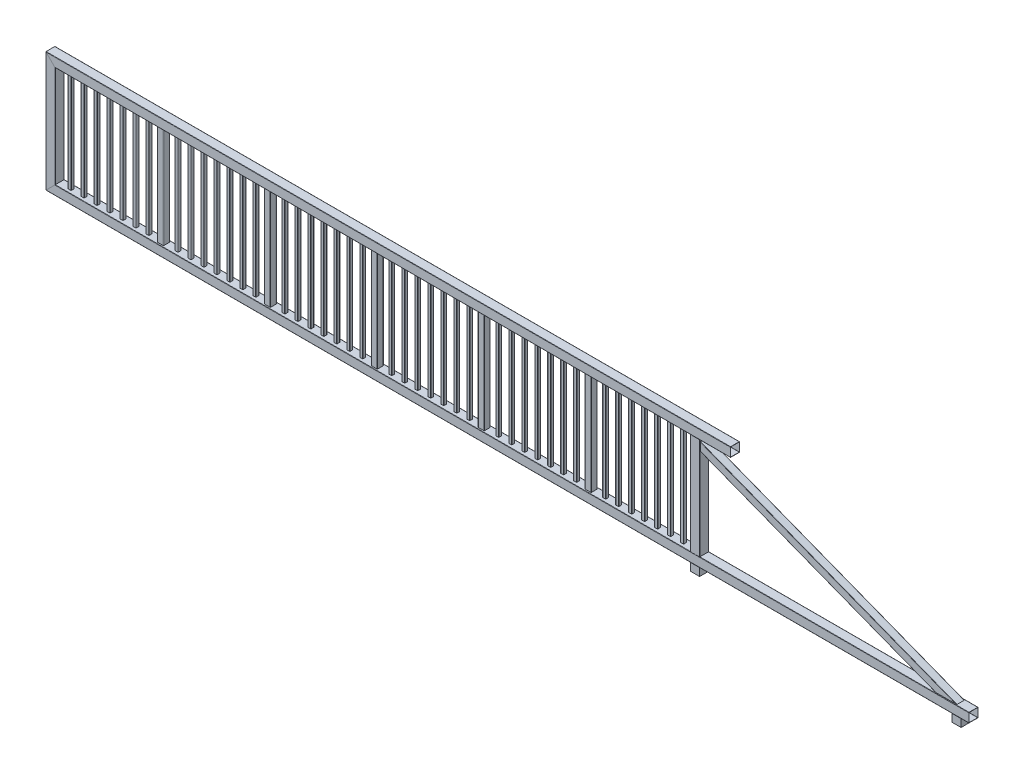
from build123d import *

# Parameters (mm, degrees)
STRUKTURBAUTEIL1_DEPTH               = 12025.852813742
STRUKTURBAUTEIL1_2_DEPTH             = 1611.705627485
STRUKTURBAUTEIL1_3_DEPTH             = 8840
STRUKTURBAUTEIL1_3_DEPTH_BACK        = 85.852813742
STRUKTURBAUTEIL1_4_DEPTH             = 1442
STRUKTURBAUTEIL2_DEPTH               = 1440
STRUKTURBAUTEIL2_2_DEPTH             = 1440
STRUKTURBAUTEIL2_3_DEPTH             = 1440
STRUKTURBAUTEIL2_4_DEPTH             = 1440
STRUKTURBAUTEIL2_5_DEPTH             = 1440
STRUKTURBAUTEIL3_DEPTH               = 3656.569430491
SKIZZE17_W                           = 97.291207045
SKIZZE17_H                           = 66.18861102
SKIZZE17_W_2                         = 105.616150556
SKIZZE17_H_2                         = 110.543827221
SCHNITT_LINEAR_AUSTRAGEN1_DEPTH      = 9026.71880794
SCHNITT_LINEAR_AUSTRAGEN1_DEPTH_BACK = 9026.71880794
STRUKTURBAUTEIL4_DEPTH               = 1320
LINEARES_MUSTER1_COUNT               = 7
LINEARES_MUSTER1_PITCH               = 168.75
LINEARES_MUSTER2_COUNT               = 6
LINEARES_MUSTER2_PITCH               = 1390
SKIZZE27_W                           = 151.392313848
SKIZZE27_H                           = 253.522757627
SCHNITT_LINEAR_AUSTRAGEN2_DEPTH      = 12035.450548322
SKIZZE28_W                           = 120
SKIZZE28_H                           = 120
AUFSATZ_LINEAR_AUSTRAGEN1_DEPTH      = 100
AUFSATZ_LINEAR_AUSTRAGEN1_2_DEPTH    = 100


with BuildPart() as part:
    # Skizze13 on segment 1 (carried to segment 1) → Strukturbauteil1 (new body)
    with BuildSketch(Plane(origin=(11940, 0, 0), x_dir=(0, -1, 0), z_dir=(-1, 0, 0))):
        with BuildLine():
            Line((56, -60), (-56, -60))
            ThreePointArc((-56, -60), (-58.828427125, -58.828427125), (-60, -56))
            Line((-60, -56), (-60, 56))
            ThreePointArc((-60, 56), (-58.828427125, 58.828427125), (-56, 60))
            Line((-56, 60), (56, 60))
            ThreePointArc((56, 60), (58.828427125, 58.828427125), (60, 56))
            Line((60, 56), (60, -56))
            ThreePointArc((60, -56), (58.828427125, -58.828427125), (56, -60))
        make_face()
        with BuildLine():
            Line((57, -56), (57, 56))
            ThreePointArc((57, 56), (56.707106781, 56.707106781), (56, 57))
            Line((56, 57), (-56, 57))
            ThreePointArc((-56, 57), (-56.707106781, 56.707106781), (-57, 56))
            Line((-57, 56), (-57, -56))
            ThreePointArc((-57, -56), (-56.707106781, -56.707106781), (-56, -57))
            Line((-56, -57), (56, -57))
            ThreePointArc((56, -57), (56.707106781, -56.707106781), (57, -56))
        make_face(mode=Mode.SUBTRACT)
    extrude(amount=STRUKTURBAUTEIL1_DEPTH)

    # Strukturbauteil1 mitre 1
    split(bisect_by=Plane(origin=(0, 0, 0), x_dir=(0.707106781, 0.707106781, 0), z_dir=(0.707106781, -0.707106781, 0)), keep=Keep.TOP)


with BuildPart() as body_2:
    # Skizze13 on segment 2 (carried to segment 2) → Strukturbauteil1 2 (new body)
    with BuildSketch(Plane(origin=(0, -85.852813742, 0), x_dir=(-1, 0, 0), z_dir=(0, 1, 0))):
        with BuildLine():
            Line((56, -60), (-56, -60))
            ThreePointArc((-56, -60), (-58.828427125, -58.828427125), (-60, -56))
            Line((-60, -56), (-60, 56))
            ThreePointArc((-60, 56), (-58.828427125, 58.828427125), (-56, 60))
            Line((-56, 60), (56, 60))
            ThreePointArc((56, 60), (58.828427125, 58.828427125), (60, 56))
            Line((60, 56), (60, -56))
            ThreePointArc((60, -56), (58.828427125, -58.828427125), (56, -60))
        make_face()
        with BuildLine():
            Line((57, -56), (57, 56))
            ThreePointArc((57, 56), (56.707106781, 56.707106781), (56, 57))
            Line((56, 57), (-56, 57))
            ThreePointArc((-56, 57), (-56.707106781, 56.707106781), (-57, 56))
            Line((-57, 56), (-57, -56))
            ThreePointArc((-57, -56), (-56.707106781, -56.707106781), (-56, -57))
            Line((-56, -57), (56, -57))
            ThreePointArc((56, -57), (56.707106781, -56.707106781), (57, -56))
        make_face(mode=Mode.SUBTRACT)
    extrude(amount=STRUKTURBAUTEIL1_2_DEPTH)

    # Strukturbauteil1 2 mitre 1
    split(bisect_by=Plane(origin=(0, 0, 0), x_dir=(-0.707106781, -0.707106781, 0), z_dir=(-0.707106781, 0.707106781, 0)), keep=Keep.TOP)

    # Strukturbauteil1 2 mitre 2
    split(bisect_by=Plane(origin=(0, 1440, 0), x_dir=(0.707106781, -0.707106781, 0), z_dir=(-0.707106781, -0.707106781, 0)), keep=Keep.TOP)


with BuildPart() as body_3:
    # Skizze13 → Strukturbauteil1 3 (new, two sides)
    with BuildSketch(Plane(origin=(0, 1440, 0), x_dir=(0, 1, 0), z_dir=(1, 0, 0))) as strukturbauteil1_3_sk:
        with BuildLine():
            Line((56, -60), (-56, -60))
            ThreePointArc((-56, -60), (-58.828427125, -58.828427125), (-60, -56))
            Line((-60, -56), (-60, 56))
            ThreePointArc((-60, 56), (-58.828427125, 58.828427125), (-56, 60))
            Line((-56, 60), (56, 60))
            ThreePointArc((56, 60), (58.828427125, 58.828427125), (60, 56))
            Line((60, 56), (60, -56))
            ThreePointArc((60, -56), (58.828427125, -58.828427125), (56, -60))
        make_face()
        with BuildLine():
            Line((57, -56), (57, 56))
            ThreePointArc((57, 56), (56.707106781, 56.707106781), (56, 57))
            Line((56, 57), (-56, 57))
            ThreePointArc((-56, 57), (-56.707106781, 56.707106781), (-57, 56))
            Line((-57, 56), (-57, -56))
            ThreePointArc((-57, -56), (-56.707106781, -56.707106781), (-56, -57))
            Line((-56, -57), (56, -57))
            ThreePointArc((56, -57), (56.707106781, -56.707106781), (57, -56))
        make_face(mode=Mode.SUBTRACT)
    extrude(amount=STRUKTURBAUTEIL1_3_DEPTH)
    extrude(strukturbauteil1_3_sk.sketch, amount=-STRUKTURBAUTEIL1_3_DEPTH_BACK)

    # Strukturbauteil1 3 mitre 1
    split(bisect_by=Plane(origin=(0, 1440, 0), x_dir=(-0.707106781, 0.707106781, 0), z_dir=(0.707106781, 0.707106781, 0)), keep=Keep.TOP)


with BuildPart() as body_4:
    # Skizze13 on segment 4 (carried to segment 4) → Strukturbauteil1 4 (new body)
    with BuildSketch(Plane(origin=(8380, 1441, 0), x_dir=(1, 0, 0), z_dir=(0, -1, 0))):
        with BuildLine():
            Line((56, -60), (-56, -60))
            ThreePointArc((-56, -60), (-58.828427125, -58.828427125), (-60, -56))
            Line((-60, -56), (-60, 56))
            ThreePointArc((-60, 56), (-58.828427125, 58.828427125), (-56, 60))
            Line((-56, 60), (56, 60))
            ThreePointArc((56, 60), (58.828427125, 58.828427125), (60, 56))
            Line((60, 56), (60, -56))
            ThreePointArc((60, -56), (58.828427125, -58.828427125), (56, -60))
        make_face()
        with BuildLine():
            Line((57, -56), (57, 56))
            ThreePointArc((57, 56), (56.707106781, 56.707106781), (56, 57))
            Line((56, 57), (-56, 57))
            ThreePointArc((-56, 57), (-56.707106781, 56.707106781), (-57, 56))
            Line((-57, 56), (-57, -56))
            ThreePointArc((-57, -56), (-56.707106781, -56.707106781), (-56, -57))
            Line((-56, -57), (56, -57))
            ThreePointArc((56, -57), (56.707106781, -56.707106781), (57, -56))
        make_face(mode=Mode.SUBTRACT)
    extrude(amount=STRUKTURBAUTEIL1_4_DEPTH)

    # Strukturbauteil1 4 mitre 1
    split(bisect_by=Plane(origin=(8380, 1380, 0), x_dir=(1, 0, 0), z_dir=(0, -1, 0)), keep=Keep.TOP)

    # Strukturbauteil1 4 mitre 2
    split(bisect_by=Plane(origin=(8380, 60, 0), x_dir=(-1, 0, 0), z_dir=(0, 1, 0)), keep=Keep.TOP)


with BuildPart() as body_5:
    # Skizze14 → Strukturbauteil2 (new body)
    with BuildSketch(Plane(origin=(1410, 1440, 0), x_dir=(1, 0, 0), z_dir=(0, -1, 0))):
        with BuildLine():
            Line((36, -40), (-36, -40))
            ThreePointArc((-36, -40), (-38.828427125, -38.828427125), (-40, -36))
            Line((-40, -36), (-40, 36))
            ThreePointArc((-40, 36), (-38.828427125, 38.828427125), (-36, 40))
            Line((-36, 40), (36, 40))
            ThreePointArc((36, 40), (38.828427125, 38.828427125), (40, 36))
            Line((40, 36), (40, -36))
            ThreePointArc((40, -36), (38.828427125, -38.828427125), (36, -40))
        make_face()
        with BuildLine():
            Line((37, -36), (37, 36))
            ThreePointArc((37, 36), (36.707106781, 36.707106781), (36, 37))
            Line((36, 37), (-36, 37))
            ThreePointArc((-36, 37), (-36.707106781, 36.707106781), (-37, 36))
            Line((-37, 36), (-37, -36))
            ThreePointArc((-37, -36), (-36.707106781, -36.707106781), (-36, -37))
            Line((-36, -37), (36, -37))
            ThreePointArc((36, -37), (36.707106781, -36.707106781), (37, -36))
        make_face(mode=Mode.SUBTRACT)
    extrude(amount=STRUKTURBAUTEIL2_DEPTH)


with BuildPart() as body_6:
    # Skizze14 on segment 2 (carried to segment 2) → Strukturbauteil2 2 (new body)
    with BuildSketch(Plane(origin=(2800, 1440, 0), x_dir=(1, 0, 0), z_dir=(0, -1, 0))):
        with BuildLine():
            Line((36, -40), (-36, -40))
            ThreePointArc((-36, -40), (-38.828427125, -38.828427125), (-40, -36))
            Line((-40, -36), (-40, 36))
            ThreePointArc((-40, 36), (-38.828427125, 38.828427125), (-36, 40))
            Line((-36, 40), (36, 40))
            ThreePointArc((36, 40), (38.828427125, 38.828427125), (40, 36))
            Line((40, 36), (40, -36))
            ThreePointArc((40, -36), (38.828427125, -38.828427125), (36, -40))
        make_face()
        with BuildLine():
            Line((37, -36), (37, 36))
            ThreePointArc((37, 36), (36.707106781, 36.707106781), (36, 37))
            Line((36, 37), (-36, 37))
            ThreePointArc((-36, 37), (-36.707106781, 36.707106781), (-37, 36))
            Line((-37, 36), (-37, -36))
            ThreePointArc((-37, -36), (-36.707106781, -36.707106781), (-36, -37))
            Line((-36, -37), (36, -37))
            ThreePointArc((36, -37), (36.707106781, -36.707106781), (37, -36))
        make_face(mode=Mode.SUBTRACT)
    extrude(amount=STRUKTURBAUTEIL2_2_DEPTH)


with BuildPart() as body_7:
    # Skizze14 on segment 3 (carried to segment 3) → Strukturbauteil2 3 (new body)
    with BuildSketch(Plane(origin=(4190, 1440, 0), x_dir=(1, 0, 0), z_dir=(0, -1, 0))):
        with BuildLine():
            Line((36, -40), (-36, -40))
            ThreePointArc((-36, -40), (-38.828427125, -38.828427125), (-40, -36))
            Line((-40, -36), (-40, 36))
            ThreePointArc((-40, 36), (-38.828427125, 38.828427125), (-36, 40))
            Line((-36, 40), (36, 40))
            ThreePointArc((36, 40), (38.828427125, 38.828427125), (40, 36))
            Line((40, 36), (40, -36))
            ThreePointArc((40, -36), (38.828427125, -38.828427125), (36, -40))
        make_face()
        with BuildLine():
            Line((37, -36), (37, 36))
            ThreePointArc((37, 36), (36.707106781, 36.707106781), (36, 37))
            Line((36, 37), (-36, 37))
            ThreePointArc((-36, 37), (-36.707106781, 36.707106781), (-37, 36))
            Line((-37, 36), (-37, -36))
            ThreePointArc((-37, -36), (-36.707106781, -36.707106781), (-36, -37))
            Line((-36, -37), (36, -37))
            ThreePointArc((36, -37), (36.707106781, -36.707106781), (37, -36))
        make_face(mode=Mode.SUBTRACT)
    extrude(amount=STRUKTURBAUTEIL2_3_DEPTH)


with BuildPart() as body_8:
    # Skizze14 on segment 4 (carried to segment 4) → Strukturbauteil2 4 (new body)
    with BuildSketch(Plane(origin=(5580, 1440, 0), x_dir=(1, 0, 0), z_dir=(0, -1, 0))):
        with BuildLine():
            Line((36, -40), (-36, -40))
            ThreePointArc((-36, -40), (-38.828427125, -38.828427125), (-40, -36))
            Line((-40, -36), (-40, 36))
            ThreePointArc((-40, 36), (-38.828427125, 38.828427125), (-36, 40))
            Line((-36, 40), (36, 40))
            ThreePointArc((36, 40), (38.828427125, 38.828427125), (40, 36))
            Line((40, 36), (40, -36))
            ThreePointArc((40, -36), (38.828427125, -38.828427125), (36, -40))
        make_face()
        with BuildLine():
            Line((37, -36), (37, 36))
            ThreePointArc((37, 36), (36.707106781, 36.707106781), (36, 37))
            Line((36, 37), (-36, 37))
            ThreePointArc((-36, 37), (-36.707106781, 36.707106781), (-37, 36))
            Line((-37, 36), (-37, -36))
            ThreePointArc((-37, -36), (-36.707106781, -36.707106781), (-36, -37))
            Line((-36, -37), (36, -37))
            ThreePointArc((36, -37), (36.707106781, -36.707106781), (37, -36))
        make_face(mode=Mode.SUBTRACT)
    extrude(amount=STRUKTURBAUTEIL2_4_DEPTH)


with BuildPart() as body_9:
    # Skizze14 on segment 5 (carried to segment 5) → Strukturbauteil2 5 (new body)
    with BuildSketch(Plane(origin=(6970, 1440, 0), x_dir=(1, 0, 0), z_dir=(0, -1, 0))):
        with BuildLine():
            Line((36, -40), (-36, -40))
            ThreePointArc((-36, -40), (-38.828427125, -38.828427125), (-40, -36))
            Line((-40, -36), (-40, 36))
            ThreePointArc((-40, 36), (-38.828427125, 38.828427125), (-36, 40))
            Line((-36, 40), (36, 40))
            ThreePointArc((36, 40), (38.828427125, 38.828427125), (40, 36))
            Line((40, 36), (40, -36))
            ThreePointArc((40, -36), (38.828427125, -38.828427125), (36, -40))
        make_face()
        with BuildLine():
            Line((37, -36), (37, 36))
            ThreePointArc((37, 36), (36.707106781, 36.707106781), (36, 37))
            Line((36, 37), (-36, 37))
            ThreePointArc((-36, 37), (-36.707106781, 36.707106781), (-37, 36))
            Line((-37, 36), (-37, -36))
            ThreePointArc((-37, -36), (-36.707106781, -36.707106781), (-36, -37))
            Line((-36, -37), (36, -37))
            ThreePointArc((36, -37), (36.707106781, -36.707106781), (37, -36))
        make_face(mode=Mode.SUBTRACT)
    extrude(amount=STRUKTURBAUTEIL2_5_DEPTH)


with BuildPart() as body_10:
    # Skizze16 → Strukturbauteil3 (new body)
    with BuildSketch(Plane(origin=(8380, 1320, 0), x_dir=(0.36099410255771225, 0.9325680982740896, 0), z_dir=(0.9325680982740896, -0.36099410255771225, 0))):
        with BuildLine():
            Line((46, -50), (-46, -50))
            ThreePointArc((-46, -50), (-48.828427125, -48.828427125), (-50, -46))
            Line((-50, -46), (-50, 46))
            ThreePointArc((-50, 46), (-48.828427125, 48.828427125), (-46, 50))
            Line((-46, 50), (46, 50))
            ThreePointArc((46, 50), (48.828427125, 48.828427125), (50, 46))
            Line((50, 46), (50, -46))
            ThreePointArc((50, -46), (48.828427125, -48.828427125), (46, -50))
        make_face()
        with BuildLine():
            Line((47, -46), (47, 46))
            ThreePointArc((47, 46), (46.707106781, 46.707106781), (46, 47))
            Line((46, 47), (-46, 47))
            ThreePointArc((-46, 47), (-46.707106781, 46.707106781), (-47, 46))
            Line((-47, 46), (-47, -46))
            ThreePointArc((-47, -46), (-46.707106781, -46.707106781), (-46, -47))
            Line((-46, -47), (46, -47))
            ThreePointArc((46, -47), (46.707106781, -46.707106781), (47, -46))
        make_face(mode=Mode.SUBTRACT)
    extrude(amount=STRUKTURBAUTEIL3_DEPTH)


with BuildPart() as schnitt_linear_austragen1_tool:
    # Skizze17 → Schnitt-Linear austragen1 (new, two sides)
    with BuildSketch(Plane(origin=(8840, 0, 0), x_dir=(0, 0, -1), z_dir=(1, 0, 0))) as schnitt_linear_austragen1_sk:
        with Locations((0.592212459, 1413.09430551)):
            Rectangle(SKIZZE17_W, SKIZZE17_H)
        with Locations((0.13209474, 4.72808639)):
            Rectangle(SKIZZE17_W_2, SKIZZE17_H_2)
    extrude(amount=SCHNITT_LINEAR_AUSTRAGEN1_DEPTH)
    extrude(schnitt_linear_austragen1_sk.sketch, amount=-SCHNITT_LINEAR_AUSTRAGEN1_DEPTH_BACK)


with BuildPart() as body_9_1:
    add(body_9.part)

    # Schnitt-Linear austragen1: cut by schnitt_linear_austragen1_tool
    add(schnitt_linear_austragen1_tool.part, mode=Mode.SUBTRACT)


with BuildPart() as body_8_1:
    add(body_8.part)

    # Schnitt-Linear austragen1: cut by schnitt_linear_austragen1_tool
    add(schnitt_linear_austragen1_tool.part, mode=Mode.SUBTRACT)


with BuildPart() as body_7_1:
    add(body_7.part)

    # Schnitt-Linear austragen1: cut by schnitt_linear_austragen1_tool
    add(schnitt_linear_austragen1_tool.part, mode=Mode.SUBTRACT)


with BuildPart() as body_6_1:
    add(body_6.part)

    # Schnitt-Linear austragen1: cut by schnitt_linear_austragen1_tool
    add(schnitt_linear_austragen1_tool.part, mode=Mode.SUBTRACT)


with BuildPart() as body_5_1:
    add(body_5.part)

    # Schnitt-Linear austragen1: cut by schnitt_linear_austragen1_tool
    add(schnitt_linear_austragen1_tool.part, mode=Mode.SUBTRACT)


with BuildPart() as body_10_1:
    add(body_10.part)

    # Schnitt-Linear austragen1: cut by schnitt_linear_austragen1_tool
    add(schnitt_linear_austragen1_tool.part, mode=Mode.SUBTRACT)

    # Skizze27 → Schnitt-Linear austragen2 (cut, through all)
    with BuildSketch(Plane.XY.offset(60)):
        with Locations((8364.303843076, 1336.173716669)):
            Rectangle(SKIZZE27_W, SKIZZE27_H)
    extrude(amount=-SCHNITT_LINEAR_AUSTRAGEN2_DEPTH, mode=Mode.SUBTRACT)


with BuildPart() as body_11:
    # Skizze19 → Strukturbauteil4 (new body)
    with BuildSketch(Plane(origin=(208.75, 1380, 0), x_dir=(1, 0, 0), z_dir=(0, -1, 0))):
        with BuildLine():
            Line((16.5, -20), (-16.5, -20))
            ThreePointArc((-16.5, -20), (-18.974873734, -18.974873734), (-20, -16.5))
            Line((-20, -16.5), (-20, 16.5))
            ThreePointArc((-20, 16.5), (-18.974873734, 18.974873734), (-16.5, 20))
            Line((-16.5, 20), (16.5, 20))
            ThreePointArc((16.5, 20), (18.974873734, 18.974873734), (20, 16.5))
            Line((20, 16.5), (20, -16.5))
            ThreePointArc((20, -16.5), (18.974873734, -18.974873734), (16.5, -20))
        make_face()
        with BuildLine():
            Line((17.5, -16.5), (17.5, 16.5))
            ThreePointArc((17.5, 16.5), (17.207106781, 17.207106781), (16.5, 17.5))
            Line((16.5, 17.5), (-16.5, 17.5))
            ThreePointArc((-16.5, 17.5), (-17.207106781, 17.207106781), (-17.5, 16.5))
            Line((-17.5, 16.5), (-17.5, -16.5))
            ThreePointArc((-17.5, -16.5), (-17.207106781, -17.207106781), (-16.5, -17.5))
            Line((-16.5, -17.5), (16.5, -17.5))
            ThreePointArc((16.5, -17.5), (17.207106781, -17.207106781), (17.5, -16.5))
        make_face(mode=Mode.SUBTRACT)
    extrude(amount=STRUKTURBAUTEIL4_DEPTH)


with BuildPart() as lineares_muster1_1:
    # Lineares Muster1: pattern copy
    add(body_11.part.moved(Location(Vector(1, 0, 0) * (1 * LINEARES_MUSTER1_PITCH))))


with BuildPart() as lineares_muster1_2:
    # Lineares Muster1: pattern copy
    add(body_11.part.moved(Location(Vector(1, 0, 0) * (2 * LINEARES_MUSTER1_PITCH))))


with BuildPart() as lineares_muster1_3:
    # Lineares Muster1: pattern copy
    add(body_11.part.moved(Location(Vector(1, 0, 0) * (3 * LINEARES_MUSTER1_PITCH))))


with BuildPart() as lineares_muster1_4:
    # Lineares Muster1: pattern copy
    add(body_11.part.moved(Location(Vector(1, 0, 0) * (4 * LINEARES_MUSTER1_PITCH))))


with BuildPart() as lineares_muster1_5:
    # Lineares Muster1: pattern copy
    add(body_11.part.moved(Location(Vector(1, 0, 0) * (5 * LINEARES_MUSTER1_PITCH))))


with BuildPart() as lineares_muster1_6:
    # Lineares Muster1: pattern copy
    add(body_11.part.moved(Location(Vector(1, 0, 0) * (6 * LINEARES_MUSTER1_PITCH))))


with BuildPart() as lineares_muster2_1:
    # Lineares Muster2: pattern copy
    add(lineares_muster1_6.part.moved(Location(Vector(1, 0, 0) * (1 * LINEARES_MUSTER2_PITCH))))


with BuildPart() as lineares_muster2_2:
    # Lineares Muster2: pattern copy
    add(lineares_muster1_6.part.moved(Location(Vector(1, 0, 0) * (2 * LINEARES_MUSTER2_PITCH))))


with BuildPart() as lineares_muster2_3:
    # Lineares Muster2: pattern copy
    add(lineares_muster1_6.part.moved(Location(Vector(1, 0, 0) * (3 * LINEARES_MUSTER2_PITCH))))


with BuildPart() as lineares_muster2_4:
    # Lineares Muster2: pattern copy
    add(lineares_muster1_6.part.moved(Location(Vector(1, 0, 0) * (4 * LINEARES_MUSTER2_PITCH))))


with BuildPart() as lineares_muster2_5:
    # Lineares Muster2: pattern copy
    add(lineares_muster1_6.part.moved(Location(Vector(1, 0, 0) * (5 * LINEARES_MUSTER2_PITCH))))


with BuildPart() as lineares_muster2_6:
    # Lineares Muster2: pattern copy
    add(lineares_muster1_5.part.moved(Location(Vector(1, 0, 0) * (1 * LINEARES_MUSTER2_PITCH))))


with BuildPart() as lineares_muster2_7:
    # Lineares Muster2: pattern copy
    add(lineares_muster1_5.part.moved(Location(Vector(1, 0, 0) * (2 * LINEARES_MUSTER2_PITCH))))


with BuildPart() as lineares_muster2_8:
    # Lineares Muster2: pattern copy
    add(lineares_muster1_5.part.moved(Location(Vector(1, 0, 0) * (3 * LINEARES_MUSTER2_PITCH))))


with BuildPart() as lineares_muster2_9:
    # Lineares Muster2: pattern copy
    add(lineares_muster1_5.part.moved(Location(Vector(1, 0, 0) * (4 * LINEARES_MUSTER2_PITCH))))


with BuildPart() as lineares_muster2_10:
    # Lineares Muster2: pattern copy
    add(lineares_muster1_5.part.moved(Location(Vector(1, 0, 0) * (5 * LINEARES_MUSTER2_PITCH))))


with BuildPart() as lineares_muster2_11:
    # Lineares Muster2: pattern copy
    add(lineares_muster1_4.part.moved(Location(Vector(1, 0, 0) * (1 * LINEARES_MUSTER2_PITCH))))


with BuildPart() as lineares_muster2_12:
    # Lineares Muster2: pattern copy
    add(lineares_muster1_4.part.moved(Location(Vector(1, 0, 0) * (2 * LINEARES_MUSTER2_PITCH))))


with BuildPart() as lineares_muster2_13:
    # Lineares Muster2: pattern copy
    add(lineares_muster1_4.part.moved(Location(Vector(1, 0, 0) * (3 * LINEARES_MUSTER2_PITCH))))


with BuildPart() as lineares_muster2_14:
    # Lineares Muster2: pattern copy
    add(lineares_muster1_4.part.moved(Location(Vector(1, 0, 0) * (4 * LINEARES_MUSTER2_PITCH))))


with BuildPart() as lineares_muster2_15:
    # Lineares Muster2: pattern copy
    add(lineares_muster1_4.part.moved(Location(Vector(1, 0, 0) * (5 * LINEARES_MUSTER2_PITCH))))


with BuildPart() as lineares_muster2_16:
    # Lineares Muster2: pattern copy
    add(lineares_muster1_3.part.moved(Location(Vector(1, 0, 0) * (1 * LINEARES_MUSTER2_PITCH))))


with BuildPart() as lineares_muster2_17:
    # Lineares Muster2: pattern copy
    add(lineares_muster1_3.part.moved(Location(Vector(1, 0, 0) * (2 * LINEARES_MUSTER2_PITCH))))


with BuildPart() as lineares_muster2_18:
    # Lineares Muster2: pattern copy
    add(lineares_muster1_3.part.moved(Location(Vector(1, 0, 0) * (3 * LINEARES_MUSTER2_PITCH))))


with BuildPart() as lineares_muster2_19:
    # Lineares Muster2: pattern copy
    add(lineares_muster1_3.part.moved(Location(Vector(1, 0, 0) * (4 * LINEARES_MUSTER2_PITCH))))


with BuildPart() as lineares_muster2_20:
    # Lineares Muster2: pattern copy
    add(lineares_muster1_3.part.moved(Location(Vector(1, 0, 0) * (5 * LINEARES_MUSTER2_PITCH))))


with BuildPart() as lineares_muster2_21:
    # Lineares Muster2: pattern copy
    add(lineares_muster1_2.part.moved(Location(Vector(1, 0, 0) * (1 * LINEARES_MUSTER2_PITCH))))


with BuildPart() as lineares_muster2_22:
    # Lineares Muster2: pattern copy
    add(lineares_muster1_2.part.moved(Location(Vector(1, 0, 0) * (2 * LINEARES_MUSTER2_PITCH))))


with BuildPart() as lineares_muster2_23:
    # Lineares Muster2: pattern copy
    add(lineares_muster1_2.part.moved(Location(Vector(1, 0, 0) * (3 * LINEARES_MUSTER2_PITCH))))


with BuildPart() as lineares_muster2_24:
    # Lineares Muster2: pattern copy
    add(lineares_muster1_2.part.moved(Location(Vector(1, 0, 0) * (4 * LINEARES_MUSTER2_PITCH))))


with BuildPart() as lineares_muster2_25:
    # Lineares Muster2: pattern copy
    add(lineares_muster1_2.part.moved(Location(Vector(1, 0, 0) * (5 * LINEARES_MUSTER2_PITCH))))


with BuildPart() as lineares_muster2_26:
    # Lineares Muster2: pattern copy
    add(lineares_muster1_1.part.moved(Location(Vector(1, 0, 0) * (1 * LINEARES_MUSTER2_PITCH))))


with BuildPart() as lineares_muster2_27:
    # Lineares Muster2: pattern copy
    add(lineares_muster1_1.part.moved(Location(Vector(1, 0, 0) * (2 * LINEARES_MUSTER2_PITCH))))


with BuildPart() as lineares_muster2_28:
    # Lineares Muster2: pattern copy
    add(lineares_muster1_1.part.moved(Location(Vector(1, 0, 0) * (3 * LINEARES_MUSTER2_PITCH))))


with BuildPart() as lineares_muster2_29:
    # Lineares Muster2: pattern copy
    add(lineares_muster1_1.part.moved(Location(Vector(1, 0, 0) * (4 * LINEARES_MUSTER2_PITCH))))


with BuildPart() as lineares_muster2_30:
    # Lineares Muster2: pattern copy
    add(lineares_muster1_1.part.moved(Location(Vector(1, 0, 0) * (5 * LINEARES_MUSTER2_PITCH))))


with BuildPart() as lineares_muster2_31:
    # Lineares Muster2: pattern copy
    add(body_11.part.moved(Location(Vector(1, 0, 0) * (1 * LINEARES_MUSTER2_PITCH))))


with BuildPart() as lineares_muster2_32:
    # Lineares Muster2: pattern copy
    add(body_11.part.moved(Location(Vector(1, 0, 0) * (2 * LINEARES_MUSTER2_PITCH))))


with BuildPart() as lineares_muster2_33:
    # Lineares Muster2: pattern copy
    add(body_11.part.moved(Location(Vector(1, 0, 0) * (3 * LINEARES_MUSTER2_PITCH))))


with BuildPart() as lineares_muster2_34:
    # Lineares Muster2: pattern copy
    add(body_11.part.moved(Location(Vector(1, 0, 0) * (4 * LINEARES_MUSTER2_PITCH))))


with BuildPart() as lineares_muster2_35:
    # Lineares Muster2: pattern copy
    add(body_11.part.moved(Location(Vector(1, 0, 0) * (5 * LINEARES_MUSTER2_PITCH))))


with BuildPart() as body_53:
    # Skizze28 → Aufsatz-Linear austragen1 (new body)
    with BuildSketch(Plane(origin=(0, -60, 0), x_dir=(-1, 0, 0), z_dir=(0, -1, 0))):
        with Locations((-8380, 0)):
            Rectangle(SKIZZE28_W, SKIZZE28_H)
    extrude(amount=AUFSATZ_LINEAR_AUSTRAGEN1_DEPTH)


with BuildPart() as body_54:
    # Skizze28 → Aufsatz-Linear austragen1 2 (new body)
    with BuildSketch(Plane(origin=(0, -60, 0), x_dir=(-1, 0, 0), z_dir=(0, -1, 0))):
        with Locations((-11780, 0)):
            Rectangle(SKIZZE28_W, SKIZZE28_H)
    extrude(amount=AUFSATZ_LINEAR_AUSTRAGEN1_2_DEPTH)


solid = Compound([part.part, body_2.part, body_3.part, body_4.part, body_9_1.part, body_8_1.part, body_7_1.part, body_6_1.part, body_5_1.part, body_10_1.part, body_11.part, lineares_muster1_1.part, lineares_muster1_2.part, lineares_muster1_3.part, lineares_muster1_4.part, lineares_muster1_5.part, lineares_muster1_6.part, lineares_muster2_1.part, lineares_muster2_2.part, lineares_muster2_3.part, lineares_muster2_4.part, lineares_muster2_5.part, lineares_muster2_6.part, lineares_muster2_7.part, lineares_muster2_8.part, lineares_muster2_9.part, lineares_muster2_10.part, lineares_muster2_11.part, lineares_muster2_12.part, lineares_muster2_13.part, lineares_muster2_14.part, lineares_muster2_15.part, lineares_muster2_16.part, lineares_muster2_17.part, lineares_muster2_18.part, lineares_muster2_19.part, lineares_muster2_20.part, lineares_muster2_21.part, lineares_muster2_22.part, lineares_muster2_23.part, lineares_muster2_24.part, lineares_muster2_25.part, lineares_muster2_26.part, lineares_muster2_27.part, lineares_muster2_28.part, lineares_muster2_29.part, lineares_muster2_30.part, lineares_muster2_31.part, lineares_muster2_32.part, lineares_muster2_33.part, lineares_muster2_34.part, lineares_muster2_35.part, body_53.part, body_54.part])
